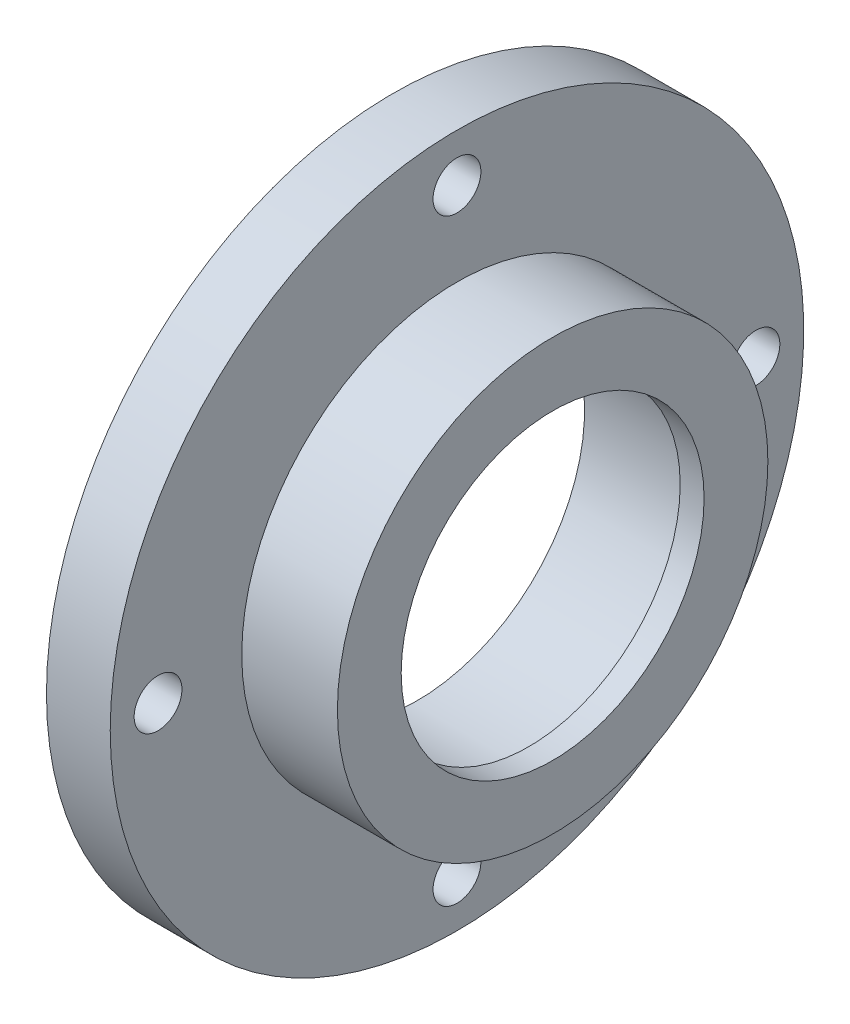
from build123d import *

# Parameters (mm, degrees)
CUT_EXTRUDE_1_REACH = 22
SKETCH_2_R          = 3


with BuildPart() as part:
    # 草图1 → 旋转1 (revolve)
    with BuildSketch(Plane(origin=(0, 0, 0), x_dir=(1, 0, 0), z_dir=(0, 1, 0))):
        Polygon((0, 30), (0, 43.5), (8, 43.5), (8, 27), (20, 27), (20, 19), (17, 19), (17, 21), (3, 21), (3, 30), align=None)
    revolve(axis=Axis((0, 0, 0), (1, 0, 0)))

    # 草图2 → 切除-拉伸1 (cut, up to next)
    with BuildSketch(Plane.ZY, mode=Mode.PRIVATE) as cut_extrude_1_sk1:
        with Locations((0, -37.5)):
            Circle(SKETCH_2_R)
    cut_extrude_1_tool1 = extrude(cut_extrude_1_sk1.sketch, amount=-CUT_EXTRUDE_1_REACH, mode=Mode.PRIVATE) & part.part
    add(cut_extrude_1_tool1.solids().sort_by_distance((0, -37.5, 0))[0], mode=Mode.SUBTRACT)
    # 草图2 → 切除-拉伸1 (cut, up to next)
    with BuildSketch(Plane.ZY, mode=Mode.PRIVATE) as cut_extrude_1_sk2:
        with Locations((0, 37.5)):
            Circle(SKETCH_2_R)
    cut_extrude_1_tool2 = extrude(cut_extrude_1_sk2.sketch, amount=-CUT_EXTRUDE_1_REACH, mode=Mode.PRIVATE) & part.part
    add(cut_extrude_1_tool2.solids().sort_by_distance((0, 37.5, 0))[0], mode=Mode.SUBTRACT)
    # 草图2 → 切除-拉伸1 (cut, up to next)
    with BuildSketch(Plane.ZY, mode=Mode.PRIVATE) as cut_extrude_1_sk3:
        with Locations((-37.5, 0)):
            Circle(SKETCH_2_R)
    cut_extrude_1_tool3 = extrude(cut_extrude_1_sk3.sketch, amount=-CUT_EXTRUDE_1_REACH, mode=Mode.PRIVATE) & part.part
    add(cut_extrude_1_tool3.solids().sort_by_distance((0, 0, -37.5))[0], mode=Mode.SUBTRACT)
    # 草图2 → 切除-拉伸1 (cut, up to next)
    with BuildSketch(Plane.ZY, mode=Mode.PRIVATE) as cut_extrude_1_sk4:
        with Locations((37.5, 0)):
            Circle(SKETCH_2_R)
    cut_extrude_1_tool4 = extrude(cut_extrude_1_sk4.sketch, amount=-CUT_EXTRUDE_1_REACH, mode=Mode.PRIVATE) & part.part
    add(cut_extrude_1_tool4.solids().sort_by_distance((0, 0, 37.5))[0], mode=Mode.SUBTRACT)


solid = part.part
